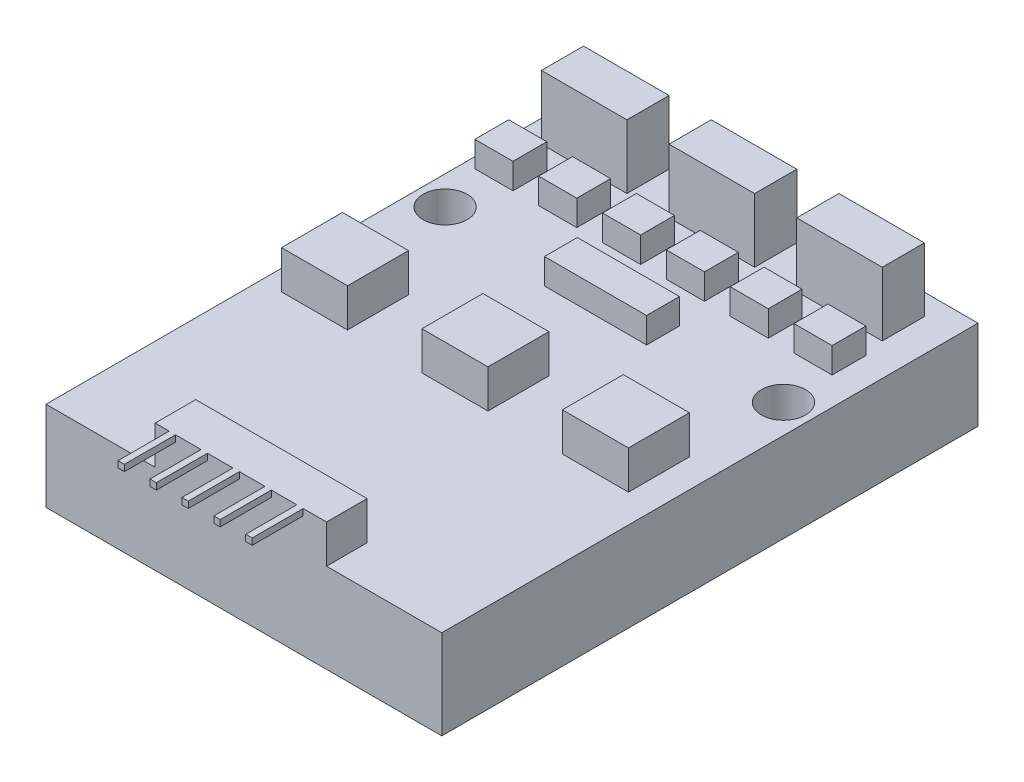
from build123d import *

# Parameters (mm, degrees)
SKETCH_1_W          = 31
SKETCH_1_H          = 42
EXTRUDE_1_DEPTH     = 7
SKETCH_3_W          = 6.699750495
SKETCH_3_H          = 3.302693905
EXTRUDE_2_DEPTH     = 5
SKETCH_4_W          = 2.984504837
SKETCH_4_H          = 2.652893189
EXTRUDE_3_DEPTH     = 2
SKETCH_5_W          = 8
SKETCH_5_H          = 2.576224576
EXTRUDE_4_DEPTH     = 2
SKETCH_6_R          = 1.726982995
CUT_EXTRUDE_1_DEPTH = 8
SKETCH_7_W          = 5.173141718
SKETCH_7_H          = 4.77520774
SKETCH_7_W_2        = 13.421733696
SKETCH_7_H_2        = 3.175273919
EXTRUDE_5_DEPTH     = 3
SKETCH_8_W          = 0.5
SKETCH_8_H          = 0.5
EXTRUDE_6_DEPTH     = 4


with BuildPart() as part:
    # 草圖1 → 填料-伸長1 (new body)
    with BuildSketch(Plane(origin=(0, 0, 0), x_dir=(1, 0, 0), z_dir=(0, 1, 0))):
        with Locations((15.5, 21)):
            Rectangle(SKETCH_1_W, SKETCH_1_H)
    extrude(amount=EXTRUDE_1_DEPTH)

    # 草圖3 → 填料-伸長2 (add)
    with BuildSketch(Plane(origin=(0, 7, 0), x_dir=(1, 0, 0), z_dir=(0, 1, 0))):
        with Locations((15.108684373, 38.694954661)):
            Rectangle(SKETCH_3_W, SKETCH_3_H)
        with Locations((5.108684373, 38.694954661)):
            Rectangle(SKETCH_3_W, SKETCH_3_H)
        with Locations((25.108684373, 38.694954661)):
            Rectangle(SKETCH_3_W, SKETCH_3_H)
    extrude(amount=EXTRUDE_2_DEPTH)

    # 草圖4 → 填料-伸長3 (add)
    with BuildSketch(Plane(origin=(0, 7, 0), x_dir=(1, 0, 0), z_dir=(0, 1, 0))):
        with Locations((7.315015434, 34.091646646)):
            Rectangle(SKETCH_4_W, SKETCH_4_H)
        with Locations((2.315015434, 34.091646646)):
            Rectangle(SKETCH_4_W, SKETCH_4_H)
        with Locations((12.315015434, 34.091646646)):
            Rectangle(SKETCH_4_W, SKETCH_4_H)
        with Locations((17.315015434, 34.091646646)):
            Rectangle(SKETCH_4_W, SKETCH_4_H)
        with Locations((22.315015434, 34.091646646)):
            Rectangle(SKETCH_4_W, SKETCH_4_H)
        with Locations((27.315015434, 34.091646646)):
            Rectangle(SKETCH_4_W, SKETCH_4_H)
    extrude(amount=EXTRUDE_3_DEPTH)

    # 草圖5 → 填料-伸長4 (add)
    with BuildSketch(Plane(origin=(0, 7, 0), x_dir=(1, 0, 0), z_dir=(0, 1, 0))):
        with Locations((15.5, 28.828363784)):
            Rectangle(SKETCH_5_W, SKETCH_5_H)
    extrude(amount=EXTRUDE_4_DEPTH)

    # 草圖6 → 除料-伸長1 (cut, through all)
    with BuildSketch(Plane(origin=(0, 7, 0), x_dir=(1, 0, 0), z_dir=(0, 1, 0))):
        with Locations((2.25, 29.011078955)):
            Circle(SKETCH_6_R)
        with Locations((28.75, 29.011078955)):
            Circle(SKETCH_6_R)
    extrude(amount=-CUT_EXTRUDE_1_DEPTH, mode=Mode.SUBTRACT)

    # 草圖7 → 填料-伸長5 (add)
    with BuildSketch(Plane(origin=(0, 7, 0), x_dir=(1, 0, 0), z_dir=(0, 1, 0))):
        with Locations((15.187222404, 19.232590782)):
            Rectangle(SKETCH_7_W, SKETCH_7_H)
        with Locations((4.187222404, 19.232590782)):
            Rectangle(SKETCH_7_W, SKETCH_7_H)
        with Locations((26.187222404, 19.232590782)):
            Rectangle(SKETCH_7_W, SKETCH_7_H)
        with Locations((15.263552758, 1.58763696)):
            Rectangle(SKETCH_7_W_2, SKETCH_7_H_2)
    extrude(amount=EXTRUDE_5_DEPTH)

    # 草圖8 → 填料-伸長6 (add)
    with BuildSketch(Plane.XY):
        with Locations((9.895624486, 9.75)):
            Rectangle(SKETCH_8_W, SKETCH_8_H)
        with Locations((12.395624486, 9.75)):
            Rectangle(SKETCH_8_W, SKETCH_8_H)
        with Locations((14.895624486, 9.75)):
            Rectangle(SKETCH_8_W, SKETCH_8_H)
        with Locations((17.395624486, 9.75)):
            Rectangle(SKETCH_8_W, SKETCH_8_H)
        with Locations((19.895624486, 9.75)):
            Rectangle(SKETCH_8_W, SKETCH_8_H)
    extrude(amount=EXTRUDE_6_DEPTH)


solid = part.part
